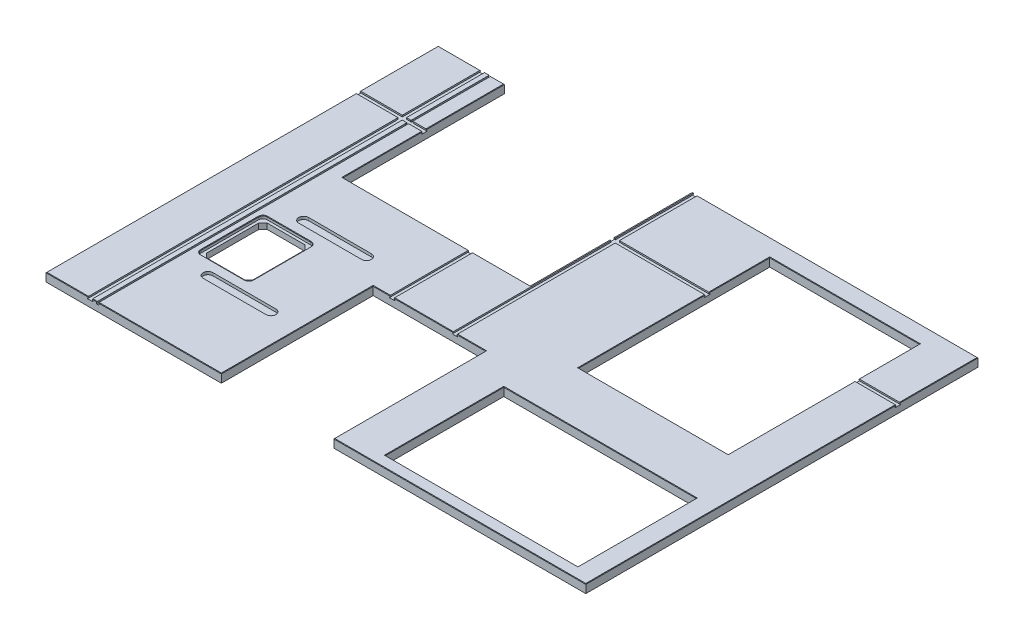
from build123d import *

# Parameters (mm, degrees)
SKETCH1_W           = 2438.4
SKETCH1_H           = 1771.65
BOSS_EXTRUDE1_DEPTH = 38.1
SKETCH2_W           = 869.95
SKETCH2_H           = 534.9875
CUT_EXTRUDE1_DEPTH  = 39.1
SKETCH3_W           = 508
SKETCH3_H           = 685.8
CUT_EXTRUDE2_DEPTH  = 39.1
SKETCH4_W           = 676.20134
SKETCH4_H           = 863.85146
CUT_EXTRUDE3_DEPTH  = 39.1
SKETCH5_W           = 846.4296
SKETCH5_H           = 730.25
CUT_EXTRUDE4_DEPTH  = 39.1
CUT_EXTRUDE5_DEPTH  = 12.7
CUT_EXTRUDE6_DEPTH  = 26.4
CUT_EXTRUDE7_DEPTH  = 1086.85
CUT_EXTRUDE8_DEPTH  = 1772.65
CUT_EXTRUDE10_DEPTH = 2439.4
CHAMFER4_SIZE       = 2.032
CUT_EXTRUDE12_DEPTH = 12.7
CUT_EXTRUDE13_DEPTH = 12.7


with BuildPart() as part:
    # Sketch1 → Boss-Extrude1 (new body)
    with BuildSketch(Plane(origin=(0, 0, 0), x_dir=(1, 0, 0), z_dir=(0, 1, 0))):
        with Locations((1219.2, 885.825)):
            Rectangle(SKETCH1_W, SKETCH1_H)
    extrude(amount=-BOSS_EXTRUDE1_DEPTH)

    # Sketch2 → Cut-Extrude1 (cut, through all)
    with BuildSketch(Plane(origin=(0, 0, 0), x_dir=(1, 0, 0), z_dir=(0, 1, 0))):
        with Locations((1917.065, 318.29375)):
            Rectangle(SKETCH2_W, SKETCH2_H)
    extrude(amount=-CUT_EXTRUDE1_DEPTH, mode=Mode.SUBTRACT)

    # Sketch3 → Cut-Extrude2 (cut, through all)
    with BuildSketch(Plane(origin=(0, 0, 0), x_dir=(1, 0, 0), z_dir=(0, 1, 0))):
        with Locations((1046.1625, 342.9)):
            Rectangle(SKETCH3_W, SKETCH3_H)
    extrude(amount=-CUT_EXTRUDE2_DEPTH, mode=Mode.SUBTRACT)

    # Sketch4 → Cut-Extrude3 (cut, through all)
    with BuildSketch(Plane(origin=(0, 0, 0), x_dir=(1, 0, 0), z_dir=(0, 1, 0))):
        with Locations((1914.52627, 1260.98427)):
            Rectangle(SKETCH4_W, SKETCH4_H)
    extrude(amount=-CUT_EXTRUDE3_DEPTH, mode=Mode.SUBTRACT)

    # Sketch5 → Cut-Extrude4 (cut, through all)
    with BuildSketch(Plane(origin=(0, 0, 0), x_dir=(1, 0, 0), z_dir=(0, 1, 0))):
        with Locations((722.3252, 1406.525)):
            Rectangle(SKETCH5_W, SKETCH5_H)
    extrude(amount=-CUT_EXTRUDE4_DEPTH, mode=Mode.SUBTRACT)

    # Sketch7 → Cut-Extrude5 (cut)
    with BuildSketch(Plane(origin=(0, 0, 0), x_dir=(1, 0, 0), z_dir=(0, 1, 0))):
        with BuildLine():
            Line((281.3685, 717.55), (478.2185, 717.55))
            ThreePointArc((478.2185, 717.55), (491.688884182, 711.970384182), (497.2685, 698.5))
            Line((497.2685, 698.5), (497.2685, 438.15))
            ThreePointArc((497.2685, 438.15), (491.688884182, 424.679615818), (478.2185, 419.1))
            Line((478.2185, 419.1), (281.3685, 419.1))
            ThreePointArc((281.3685, 419.1), (267.898115818, 424.679615818), (262.3185, 438.15))
            Line((262.3185, 438.15), (262.3185, 698.5))
            ThreePointArc((262.3185, 698.5), (267.898115818, 711.970384182), (281.3685, 717.55))
        make_face()
    extrude(amount=-CUT_EXTRUDE5_DEPTH, mode=Mode.SUBTRACT)

    # Sketch8 → Cut-Extrude6 (cut, through all)
    with BuildSketch(Plane(origin=(0, -12.7, 0), x_dir=(1, 0, 0), z_dir=(0, 1, 0))):
        Polygon((294.0685, 704.85), (275.0185, 685.8), (275.0185, 450.85), (294.0685, 431.8), (465.5185, 431.8), (484.5685, 450.85), (484.5685, 685.8), (465.5185, 704.85), align=None)
    extrude(amount=-CUT_EXTRUDE6_DEPTH, mode=Mode.SUBTRACT)

    # Sketch10 → Cut-Extrude7 (cut, through all)
    with BuildSketch(Plane.XY.offset(-685.8)):
        Polygon((1171.3083, 0), (1152.2583, 0), (1152.2583, -6.0452), (1149.6421, -6.0452), (1149.6421, -9.525), (1173.9245, -9.525), (1173.9245, -6.0452), (1171.3083, -6.0452), align=None)
        Polygon((889.7493, -9.525), (865.4669, -9.525), (865.4669, -6.0452), (868.0831, -6.0452), (868.0831, 0), (887.1331, 0), (887.1331, -6.0452), (889.7493, -6.0452), align=None)
    extrude(amount=-CUT_EXTRUDE7_DEPTH, mode=Mode.SUBTRACT)

    # Sketch12 → Cut-Extrude8 (cut, through all)
    with BuildSketch(Plane.XY):
        Polygon((209.2579, 0), (190.2079, 0), (190.2079, -6.096), (187.7949, -6.096), (187.7949, -9.525), (211.6709, -9.525), (211.6709, -6.096), (209.2579, -6.096), align=None)
        Polygon((237.4519, 0), (230.0859, 0), (230.0859, -2.54), (228.0539, -2.54), (228.0539, -9.525), (239.4839, -9.525), (239.4839, -2.54), (237.4519, -2.54), align=None)
    extrude(amount=-CUT_EXTRUDE8_DEPTH, mode=Mode.SUBTRACT)

    # Sketch16 → Cut-Extrude10 (cut, through all)
    with BuildSketch(Plane.ZY):
        Polygon((-1421.892, -9.525), (-1397.508, -9.525), (-1397.508, -5.969), (-1400.175, -5.969), (-1400.175, 0), (-1419.225, 0), (-1419.225, -5.969), (-1421.892, -5.969), align=None)
    extrude(amount=-CUT_EXTRUDE10_DEPTH, mode=Mode.SUBTRACT)

    # Chamfer4
    chamfer4_edges = [part.edges().sort_by_distance(p)[0] for p in [
        (1016.33655, 0, -1041.4),
        (1019.6957, 0, -685.8),
        (830.1228, 0, -685.8),
        (219.6719, 0, 0),
        (514.8072, 0, 0),
        (2352.04, 0, -318.29375),
        (95.10395, 0, -1771.65),
        (1917.065, 0, -585.7875),
        (1482.09, 0, -318.29375),
        (1917.065, 0, -50.8),
        (1145.54, 0, -1595.4375),
        (299.1104, 0, -1220.7875),
        (1576.4256, 0, -1114.61677),
        (2252.62694, 0, -1556.0675),
        (1869.28125, 0, 0),
        (2438.4, 0, -1595.4375),
        (0, 0, -700.0875),
        (792.1625, 0, -342.9),
        (1300.1625, 0, -342.9),
        (1235.7354, 0, -685.8),
        (0, 0, -1595.4375),
        (1804.85415, 0, -1771.65),
        (2252.62694, 0, -1114.61677),
        (1914.52627, 0, -1692.91),
        (1576.4256, 0, -1556.0675),
        (1914.52627, 0, -829.05854),
        (2438.4, 0, -700.0875),
        (95.10395, 0, 0),
        (268.28115, 0, -1771.65),
        (299.1104, 0, -1595.4375),
        (583.59675, 0, -1041.4),
        (1145.54, 0, -1220.7875),
        (491.688884182, 0, -424.679615818),
        (497.2685, 0, -568.325),
        (491.688884182, 0, -711.970384182),
        (379.7935, 0, -717.55),
        (267.898115818, 0, -711.970384182),
        (262.3185, 0, -568.325),
        (267.898115818, 0, -424.679615818),
        (379.7935, 0, -419.1),
    ]]
    chamfer(chamfer4_edges, length=CHAMFER4_SIZE)

    # Sketch17 → Cut-Extrude12 (cut)
    with BuildSketch(Plane(origin=(0, 0, 0), x_dir=(1, 0, 0), z_dir=(0, 1, 0))):
        with BuildLine():
            Line((378.53038292, 763.042172), (662.463619231, 763.042172))
            ThreePointArc((662.463619231, 763.042172), (684.684727521, 785.263280291), (662.463619231, 807.484388581))
            Line((662.463619231, 807.484388581), (378.53038292, 807.484388581))
            ThreePointArc((378.53038292, 807.484388581), (356.309274629, 785.263280291), (378.53038292, 763.042172))
        make_face()
    extrude(amount=-CUT_EXTRUDE12_DEPTH, mode=Mode.SUBTRACT)

    # Sketch18 → Cut-Extrude13 (cut)
    with BuildSketch(Plane(origin=(0, 0, 0), x_dir=(1, 0, 0), z_dir=(0, 1, 0))):
        with BuildLine():
            Line((378.53038292, 375.684388581), (662.463619231, 375.684388581))
            ThreePointArc((662.463619231, 375.684388581), (684.684727521, 353.463280291), (662.463619231, 331.242172))
            Line((662.463619231, 331.242172), (378.53038292, 331.242172))
            ThreePointArc((378.53038292, 331.242172), (356.309274629, 353.463280291), (378.53038292, 375.684388581))
        make_face()
    extrude(amount=-CUT_EXTRUDE13_DEPTH, mode=Mode.SUBTRACT)


solid = part.part
